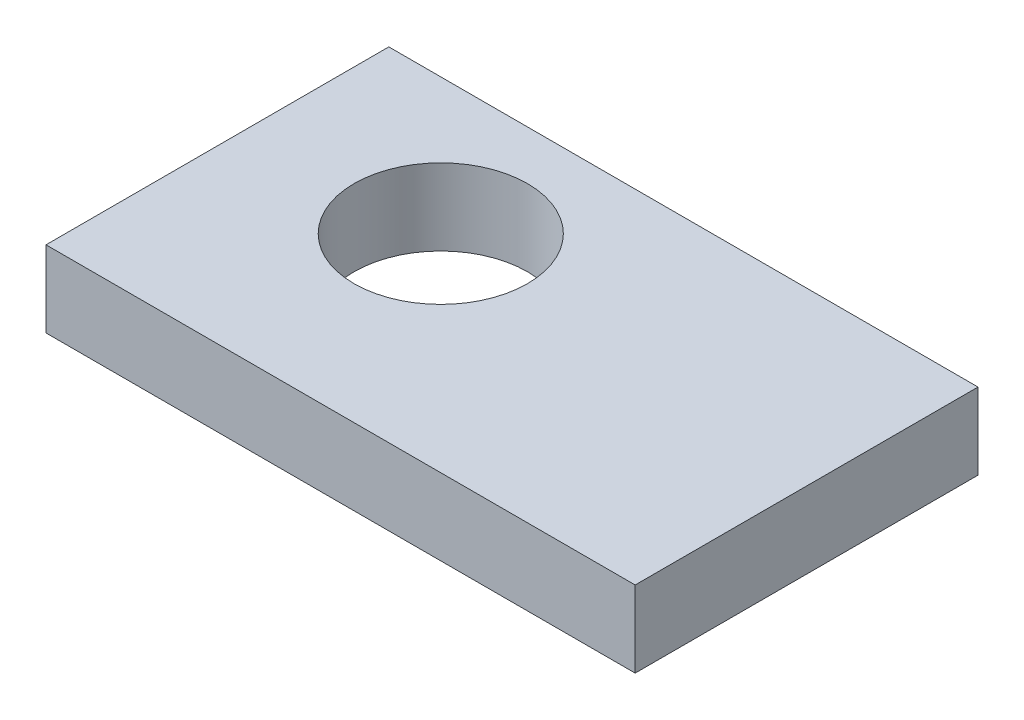
from build123d import *

# Parameters (mm, degrees)
SKETCH1_W           = 77.160601623
SKETCH1_H           = 44.898329167
BOSS_EXTRUDE1_DEPTH = 10
SKETCH2_R           = 11.353615653
CUT_EXTRUDE1_DEPTH  = 10


with BuildPart() as part:
    # Sketch1 → Boss-Extrude1 (new body)
    with BuildSketch(Plane(origin=(0, 0, 0), x_dir=(1, 0, 0), z_dir=(0, 1, 0))):
        with Locations((-16.668840769, 5.108193139)):
            Rectangle(SKETCH1_W, SKETCH1_H)
    extrude(amount=BOSS_EXTRUDE1_DEPTH)

    # Sketch2 → Cut-Extrude1 (cut)
    with BuildSketch(Plane(origin=(0, 10, 0), x_dir=(1, 0, 0), z_dir=(0, 1, 0))):
        with Locations((-30.666389333, 9.777294834)):
            Circle(SKETCH2_R)
    extrude(amount=-CUT_EXTRUDE1_DEPTH, mode=Mode.SUBTRACT)


solid = part.part
